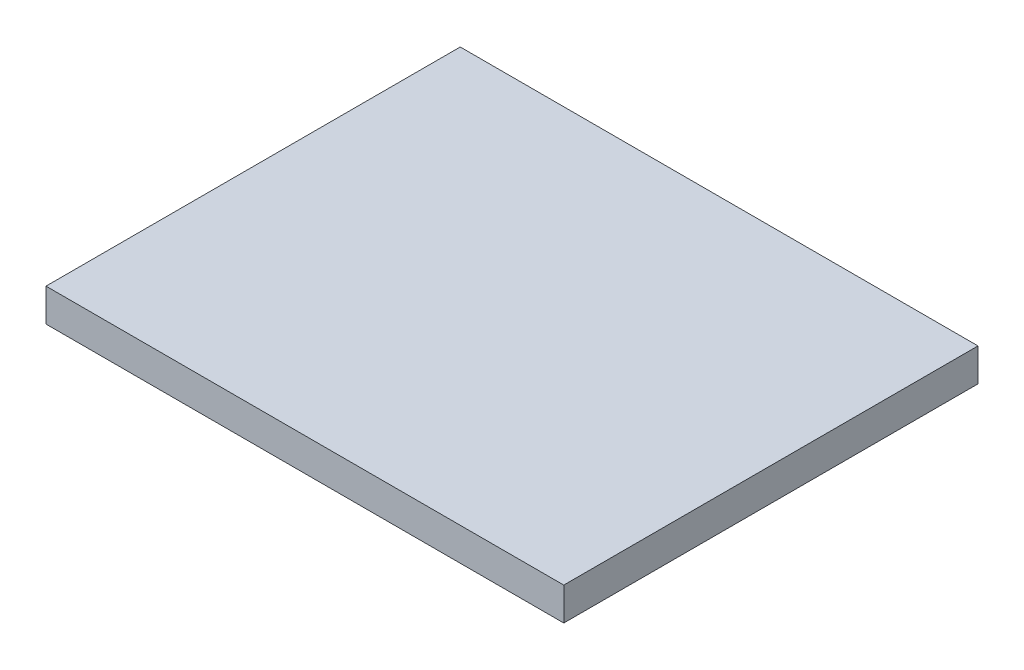
from build123d import *

# Parameters (mm, degrees)
SKETCH1_W           = 100
SKETCH1_H           = 80
BOSS_EXTRUDE1_DEPTH = 6.35


with BuildPart() as part:
    # Sketch1 → Boss-Extrude1 (new body)
    with BuildSketch(Plane(origin=(0, 0, 0), x_dir=(1, 0, 0), z_dir=(0, 1, 0))):
        with Locations((50, 40)):
            Rectangle(SKETCH1_W, SKETCH1_H)
    extrude(amount=BOSS_EXTRUDE1_DEPTH)


solid = part.part
